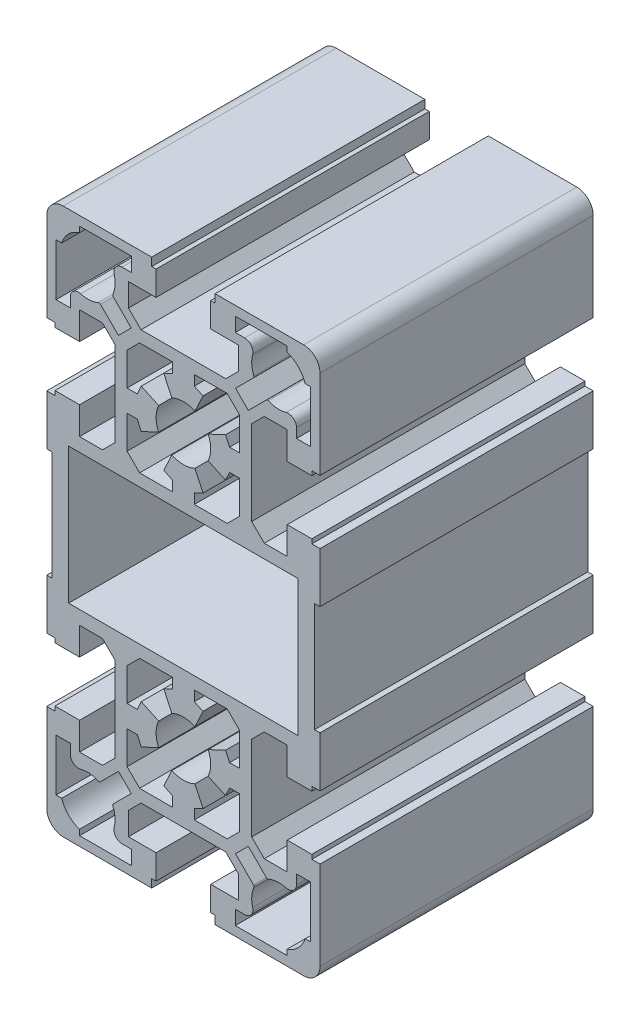
from build123d import *

# Parameters (mm, degrees)
SKETCH1_W          = 42
SKETCH1_H          = 24.9
BASE_EXTRUDE_DEPTH = 50


with BuildPart() as part:
    # Sketch1 → Base-Extrude (new body)
    with BuildSketch(Plane.XY):
        with BuildLine():
            Line((25, 72), (25, 55.8))
            Line((25, 55.8), (23.5, 55.8))
            Line((23.5, 55.8), (23.5, 55))
            Line((23.5, 55), (19, 55))
            Line((19, 55), (19, 60.05))
            Line((19, 60.05), (14.8, 60.05))
            Line((14.8, 60.05), (12.5, 57.75))
            Line((12.5, 57.75), (12.5, 42.25))
            Line((12.5, 42.25), (14.8, 39.95))
            Line((14.8, 39.95), (19, 39.95))
            Line((19, 39.95), (19, 45))
            Line((19, 45), (23.5, 45))
            Line((23.5, 45), (23.5, 44.2))
            Line((23.5, 44.2), (25, 44.2))
            Line((25, 44.2), (25, 35))
            Line((25, 35), (24, 35))
            Line((24, 35), (24, 15))
            Line((24, 15), (25, 15))
            Line((25, 15), (25, 5.8))
            Line((25, 5.8), (23.5, 5.8))
            Line((23.5, 5.8), (23.5, 5))
            Line((23.5, 5), (19, 5))
            Line((19, 5), (19, 10.05))
            Line((19, 10.05), (14.8, 10.05))
            Line((14.8, 10.05), (12.5, 7.75))
            Line((12.5, 7.75), (12.5, -7.75))
            Line((12.5, -7.75), (14.8, -10.05))
            Line((14.8, -10.05), (19, -10.05))
            Line((19, -10.05), (19, -5))
            Line((19, -5), (23.5, -5))
            Line((23.5, -5), (23.5, -5.8))
            Line((23.5, -5.8), (25, -5.8))
            Line((25, -5.8), (25, -22))
            ThreePointArc((25, -22), (24.121320344, -24.121320344), (22, -25))
            Line((22, -25), (5.8, -25))
            Line((5.8, -25), (5.8, -23.5))
            Line((5.8, -23.5), (5, -23.5))
            Line((5, -23.5), (5, -19))
            Line((5, -19), (10.05, -19))
            Line((10.05, -19), (10.05, -14.8))
            Line((10.05, -14.8), (7.75, -12.5))
            Line((7.75, -12.5), (-7.75, -12.5))
            Line((-7.75, -12.5), (-10.05, -14.8))
            Line((-10.05, -14.8), (-10.05, -19))
            Line((-10.05, -19), (-5, -19))
            Line((-5, -19), (-5, -23.5))
            Line((-5, -23.5), (-5.8, -23.5))
            Line((-5.8, -23.5), (-5.8, -25))
            Line((-5.8, -25), (-22, -25))
            ThreePointArc((-22, -25), (-24.121320344, -24.121320344), (-25, -22))
            Line((-25, -22), (-25, -5.8))
            Line((-25, -5.8), (-23.5, -5.8))
            Line((-23.5, -5.8), (-23.5, -5))
            Line((-23.5, -5), (-19, -5))
            Line((-19, -5), (-19, -10.05))
            Line((-19, -10.05), (-14.8, -10.05))
            Line((-14.8, -10.05), (-12.5, -7.75))
            Line((-12.5, -7.75), (-12.5, 7.75))
            Line((-12.5, 7.75), (-14.8, 10.05))
            Line((-14.8, 10.05), (-19, 10.05))
            Line((-19, 10.05), (-19, 5))
            Line((-19, 5), (-23.5, 5))
            Line((-23.5, 5), (-23.5, 5.8))
            Line((-23.5, 5.8), (-25, 5.8))
            Line((-25, 5.8), (-25, 15))
            Line((-25, 15), (-24, 15))
            Line((-24, 15), (-24, 35))
            Line((-24, 35), (-25, 35))
            Line((-25, 35), (-25, 44.2))
            Line((-25, 44.2), (-23.5, 44.2))
            Line((-23.5, 44.2), (-23.5, 45))
            Line((-23.5, 45), (-19, 45))
            Line((-19, 45), (-19, 39.95))
            Line((-19, 39.95), (-14.8, 39.95))
            Line((-14.8, 39.95), (-12.5, 42.25))
            Line((-12.5, 42.25), (-12.5, 57.75))
            Line((-12.5, 57.75), (-14.8, 60.05))
            Line((-14.8, 60.05), (-19, 60.05))
            Line((-19, 60.05), (-19, 55))
            Line((-19, 55), (-23.5, 55))
            Line((-23.5, 55), (-23.5, 55.8))
            Line((-23.5, 55.8), (-25, 55.8))
            Line((-25, 55.8), (-25, 72))
            ThreePointArc((-25, 72), (-24.121320344, 74.121320344), (-22, 75))
            Line((-22, 75), (-5.8, 75))
            Line((-5.8, 75), (-5.8, 73.5))
            Line((-5.8, 73.5), (-5, 73.5))
            Line((-5, 73.5), (-5, 69))
            Line((-5, 69), (-10.05, 69))
            Line((-10.05, 69), (-10.05, 64.8))
            Line((-10.05, 64.8), (-7.75, 62.5))
            Line((-7.75, 62.5), (7.75, 62.5))
            Line((7.75, 62.5), (10.05, 64.8))
            Line((10.05, 64.8), (10.05, 69))
            Line((10.05, 69), (5, 69))
            Line((5, 69), (5, 73.5))
            Line((5, 73.5), (5.8, 73.5))
            Line((5.8, 73.5), (5.8, 75))
            Line((5.8, 75), (22, 75))
            ThreePointArc((22, 75), (24.121320344, 74.121320344), (25, 72))
        make_face()
        with BuildLine():
            Line((9.538856429, 61.884693373), (12.844749681, 65.190586625))
            ThreePointArc((12.844749681, 65.190586625), (12.927259816, 65.346274066), (12.908129855, 65.521432697))
            ThreePointArc((12.908129855, 65.521432697), (12.512637816, 67.144727644), (12.674034726, 68.807692308))
            ThreePointArc((12.674034726, 68.807692308), (12.417559866, 70.11146543), (11.226245143, 70.7))
            Line((11.226245143, 70.7), (9.5, 70.7))
            Line((9.5, 70.7), (9.5, 73.3))
            Line((9.5, 73.3), (19, 73.3))
            Line((19, 73.3), (19, 72.269696007))
            ThreePointArc((19, 72.269696007), (21.035533906, 71.035533906), (22.269696007, 69))
            Line((22.269696007, 69), (23.3, 69))
            Line((23.3, 69), (23.3, 59.5))
            Line((23.3, 59.5), (20.7, 59.5))
            Line((20.7, 59.5), (20.7, 61.226245143))
            ThreePointArc((20.7, 61.226245143), (20.11146543, 62.417559866), (18.807692308, 62.674034726))
            ThreePointArc((18.807692308, 62.674034726), (17.144727644, 62.512637816), (15.521432697, 62.908129855))
            ThreePointArc((15.521432697, 62.908129855), (15.346274066, 62.927259816), (15.190586625, 62.844749681))
            Line((15.190586625, 62.844749681), (11.884693373, 59.538856429))
            Line((11.884693373, 59.538856429), (9.538856429, 61.884693373))
        make_face(mode=Mode.SUBTRACT)
        with BuildLine():
            Line((-12.844749681, 65.190586625), (-9.538856429, 61.884693373))
            Line((-9.538856429, 61.884693373), (-11.884693373, 59.538856429))
            Line((-11.884693373, 59.538856429), (-15.190586625, 62.844749681))
            ThreePointArc((-15.190586625, 62.844749681), (-15.346274066, 62.927259816), (-15.521432697, 62.908129855))
            ThreePointArc((-15.521432697, 62.908129855), (-17.144727644, 62.512637816), (-18.807692308, 62.674034726))
            ThreePointArc((-18.807692308, 62.674034726), (-20.11146543, 62.417559866), (-20.7, 61.226245143))
            Line((-20.7, 61.226245143), (-20.7, 59.5))
            Line((-20.7, 59.5), (-23.3, 59.5))
            Line((-23.3, 59.5), (-23.3, 69))
            Line((-23.3, 69), (-22.269696007, 69))
            ThreePointArc((-22.269696007, 69), (-21.035533906, 71.035533906), (-19, 72.269696007))
            Line((-19, 72.269696007), (-19, 73.3))
            Line((-19, 73.3), (-9.5, 73.3))
            Line((-9.5, 73.3), (-9.5, 70.7))
            Line((-9.5, 70.7), (-11.226245143, 70.7))
            ThreePointArc((-11.226245143, 70.7), (-12.417559866, 70.11146543), (-12.674034726, 68.807692308))
            ThreePointArc((-12.674034726, 68.807692308), (-12.512637816, 67.144727644), (-12.908129855, 65.521432697))
            ThreePointArc((-12.908129855, 65.521432697), (-12.927259816, 65.346274066), (-12.844749681, 65.190586625))
        make_face(mode=Mode.SUBTRACT)
        with BuildLine():
            Line((2, 60.3), (8.012279964, 60.3))
            Line((8.012279964, 60.3), (10.3, 58.012279964))
            Line((10.3, 58.012279964), (10.3, 52))
            Line((10.3, 52), (8.446096995, 52))
            Line((8.446096995, 52), (7.70361619, 53.592255225))
            Line((7.70361619, 53.592255225), (4.531538935, 52.113091309))
            ThreePointArc((4.531538935, 52.113091309), (5, 50), (4.531538935, 47.886908691))
            Line((4.531538935, 47.886908691), (7.70361619, 46.407744775))
            Line((7.70361619, 46.407744775), (8.446096995, 48))
            Line((8.446096995, 48), (10.3, 48))
            Line((10.3, 48), (10.3, 41.987720036))
            Line((10.3, 41.987720036), (8.012279964, 39.7))
            Line((8.012279964, 39.7), (2, 39.7))
            Line((2, 39.7), (2, 41.553903005))
            Line((2, 41.553903005), (3.592255225, 42.29638381))
            Line((3.592255225, 42.29638381), (2.113091309, 45.468461065))
            ThreePointArc((2.113091309, 45.468461065), (0, 45), (-2.113091309, 45.468461065))
            Line((-2.113091309, 45.468461065), (-3.592255225, 42.29638381))
            Line((-3.592255225, 42.29638381), (-2, 41.553903005))
            Line((-2, 41.553903005), (-2, 39.7))
            Line((-2, 39.7), (-8.012279964, 39.7))
            Line((-8.012279964, 39.7), (-10.3, 41.987720036))
            Line((-10.3, 41.987720036), (-10.3, 48))
            Line((-10.3, 48), (-8.446096995, 48))
            Line((-8.446096995, 48), (-7.70361619, 46.407744775))
            Line((-7.70361619, 46.407744775), (-4.531538935, 47.886908691))
            ThreePointArc((-4.531538935, 47.886908691), (-5, 50), (-4.531538935, 52.113091309))
            Line((-4.531538935, 52.113091309), (-7.70361619, 53.592255225))
            Line((-7.70361619, 53.592255225), (-8.446096995, 52))
            Line((-8.446096995, 52), (-10.3, 52))
            Line((-10.3, 52), (-10.3, 58.012279964))
            Line((-10.3, 58.012279964), (-8.012279964, 60.3))
            Line((-8.012279964, 60.3), (-2, 60.3))
            Line((-2, 60.3), (-2, 58.446096995))
            Line((-2, 58.446096995), (-3.592255225, 57.70361619))
            Line((-3.592255225, 57.70361619), (-2.113091309, 54.531538935))
            ThreePointArc((-2.113091309, 54.531538935), (0, 55), (2.113091309, 54.531538935))
            Line((2.113091309, 54.531538935), (3.592255225, 57.70361619))
            Line((3.592255225, 57.70361619), (2, 58.446096995))
            Line((2, 58.446096995), (2, 60.3))
        make_face(mode=Mode.SUBTRACT)
        with BuildLine():
            Line((8.012279964, -10.3), (2, -10.3))
            Line((2, -10.3), (2, -8.446096995))
            Line((2, -8.446096995), (3.592255225, -7.70361619))
            Line((3.592255225, -7.70361619), (2.113091309, -4.531538935))
            ThreePointArc((2.113091309, -4.531538935), (0, -5), (-2.113091309, -4.531538935))
            Line((-2.113091309, -4.531538935), (-3.592255225, -7.70361619))
            Line((-3.592255225, -7.70361619), (-2, -8.446096995))
            Line((-2, -8.446096995), (-2, -10.3))
            Line((-2, -10.3), (-8.012279964, -10.3))
            Line((-8.012279964, -10.3), (-10.3, -8.012279964))
            Line((-10.3, -8.012279964), (-10.3, -2))
            Line((-10.3, -2), (-8.446096995, -2))
            Line((-8.446096995, -2), (-7.70361619, -3.592255225))
            Line((-7.70361619, -3.592255225), (-4.531538935, -2.113091309))
            ThreePointArc((-4.531538935, -2.113091309), (-5, 0), (-4.531538935, 2.113091309))
            Line((-4.531538935, 2.113091309), (-7.70361619, 3.592255225))
            Line((-7.70361619, 3.592255225), (-8.446096995, 2))
            Line((-8.446096995, 2), (-10.3, 2))
            Line((-10.3, 2), (-10.3, 8.012279964))
            Line((-10.3, 8.012279964), (-8.012279964, 10.3))
            Line((-8.012279964, 10.3), (-2, 10.3))
            Line((-2, 10.3), (-2, 8.446096995))
            Line((-2, 8.446096995), (-3.592255225, 7.70361619))
            Line((-3.592255225, 7.70361619), (-2.113091309, 4.531538935))
            ThreePointArc((-2.113091309, 4.531538935), (0, 5), (2.113091309, 4.531538935))
            Line((2.113091309, 4.531538935), (3.592255225, 7.70361619))
            Line((3.592255225, 7.70361619), (2, 8.446096995))
            Line((2, 8.446096995), (2, 10.3))
            Line((2, 10.3), (8.012279964, 10.3))
            Line((8.012279964, 10.3), (10.3, 8.012279964))
            Line((10.3, 8.012279964), (10.3, 2))
            Line((10.3, 2), (8.446096995, 2))
            Line((8.446096995, 2), (7.70361619, 3.592255225))
            Line((7.70361619, 3.592255225), (4.531538935, 2.113091309))
            ThreePointArc((4.531538935, 2.113091309), (5, 0), (4.531538935, -2.113091309))
            Line((4.531538935, -2.113091309), (7.70361619, -3.592255225))
            Line((7.70361619, -3.592255225), (8.446096995, -2))
            Line((8.446096995, -2), (10.3, -2))
            Line((10.3, -2), (10.3, -8.012279964))
            Line((10.3, -8.012279964), (8.012279964, -10.3))
        make_face(mode=Mode.SUBTRACT)
        with Locations((0, 25)):
            Rectangle(SKETCH1_W, SKETCH1_H, mode=Mode.SUBTRACT)
        with BuildLine():
            Line((-23.3, -19), (-23.3, -9.5))
            Line((-23.3, -9.5), (-20.7, -9.5))
            Line((-20.7, -9.5), (-20.7, -11.226245143))
            ThreePointArc((-20.7, -11.226245143), (-20.11146543, -12.417559866), (-18.807692308, -12.674034726))
            ThreePointArc((-18.807692308, -12.674034726), (-17.144727644, -12.512637816), (-15.521432697, -12.908129855))
            ThreePointArc((-15.521432697, -12.908129855), (-15.346274066, -12.927259816), (-15.190586625, -12.844749681))
            Line((-15.190586625, -12.844749681), (-11.884693373, -9.538856429))
            Line((-11.884693373, -9.538856429), (-9.538856429, -11.884693373))
            Line((-9.538856429, -11.884693373), (-12.844749681, -15.190586625))
            ThreePointArc((-12.844749681, -15.190586625), (-12.927259816, -15.346274066), (-12.908129855, -15.521432697))
            ThreePointArc((-12.908129855, -15.521432697), (-12.512637816, -17.144727644), (-12.674034726, -18.807692308))
            ThreePointArc((-12.674034726, -18.807692308), (-12.417559866, -20.11146543), (-11.226245143, -20.7))
            Line((-11.226245143, -20.7), (-9.5, -20.7))
            Line((-9.5, -20.7), (-9.5, -23.3))
            Line((-9.5, -23.3), (-19, -23.3))
            Line((-19, -23.3), (-19, -22.269696007))
            ThreePointArc((-19, -22.269696007), (-21.035533906, -21.035533906), (-22.269696007, -19))
            Line((-22.269696007, -19), (-23.3, -19))
        make_face(mode=Mode.SUBTRACT)
        with BuildLine():
            Line((23.3, -9.5), (23.3, -19))
            Line((23.3, -19), (22.269696007, -19))
            ThreePointArc((22.269696007, -19), (21.035533906, -21.035533906), (19, -22.269696007))
            Line((19, -22.269696007), (19, -23.3))
            Line((19, -23.3), (9.5, -23.3))
            Line((9.5, -23.3), (9.5, -20.7))
            Line((9.5, -20.7), (11.226245143, -20.7))
            ThreePointArc((11.226245143, -20.7), (12.417559866, -20.11146543), (12.674034726, -18.807692308))
            ThreePointArc((12.674034726, -18.807692308), (12.512637816, -17.144727644), (12.908129855, -15.521432697))
            ThreePointArc((12.908129855, -15.521432697), (12.927259816, -15.346274066), (12.844749681, -15.190586625))
            Line((12.844749681, -15.190586625), (9.538856429, -11.884693373))
            Line((9.538856429, -11.884693373), (11.884693373, -9.538856429))
            Line((11.884693373, -9.538856429), (15.190586625, -12.844749681))
            ThreePointArc((15.190586625, -12.844749681), (15.346274066, -12.927259816), (15.521432697, -12.908129855))
            ThreePointArc((15.521432697, -12.908129855), (17.144727644, -12.512637816), (18.807692308, -12.674034726))
            ThreePointArc((18.807692308, -12.674034726), (20.11146543, -12.417559866), (20.7, -11.226245143))
            Line((20.7, -11.226245143), (20.7, -9.5))
            Line((20.7, -9.5), (23.3, -9.5))
        make_face(mode=Mode.SUBTRACT)
    extrude(amount=BASE_EXTRUDE_DEPTH)


solid = part.part
